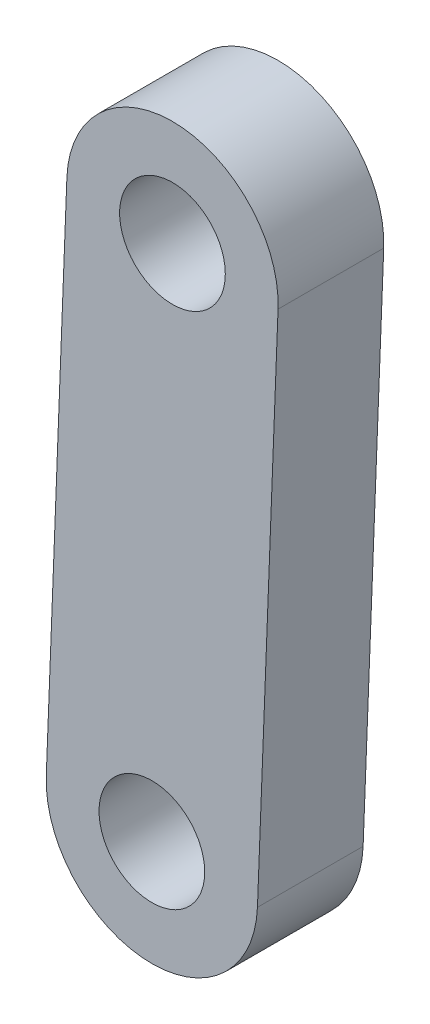
from build123d import *

# Parameters (mm, degrees)
SKETCH1_R           = 5
BOSS_EXTRUDE1_DEPTH = 10


with BuildPart() as part:
    # Sketch1 → Boss-Extrude1 (new body)
    with BuildSketch(Plane.XY):
        with BuildLine():
            Line((9.992410195, -0.389536259), (8.043249523, -50.389536259))
            ThreePointArc((8.043249523, -50.389536259), (-2.338696931, -59.992410195), (-11.941570866, -49.610463741))
            Line((-11.941570866, -49.610463741), (-9.992410195, 0.389536259))
            ThreePointArc((-9.992410195, 0.389536259), (0.389536259, 9.992410195), (9.992410195, -0.389536259))
        make_face()
        with Locations((-1.949160671, -50)):
            Circle(SKETCH1_R, mode=Mode.SUBTRACT)
        Circle(SKETCH1_R, mode=Mode.SUBTRACT)
    extrude(amount=BOSS_EXTRUDE1_DEPTH)


solid = part.part
